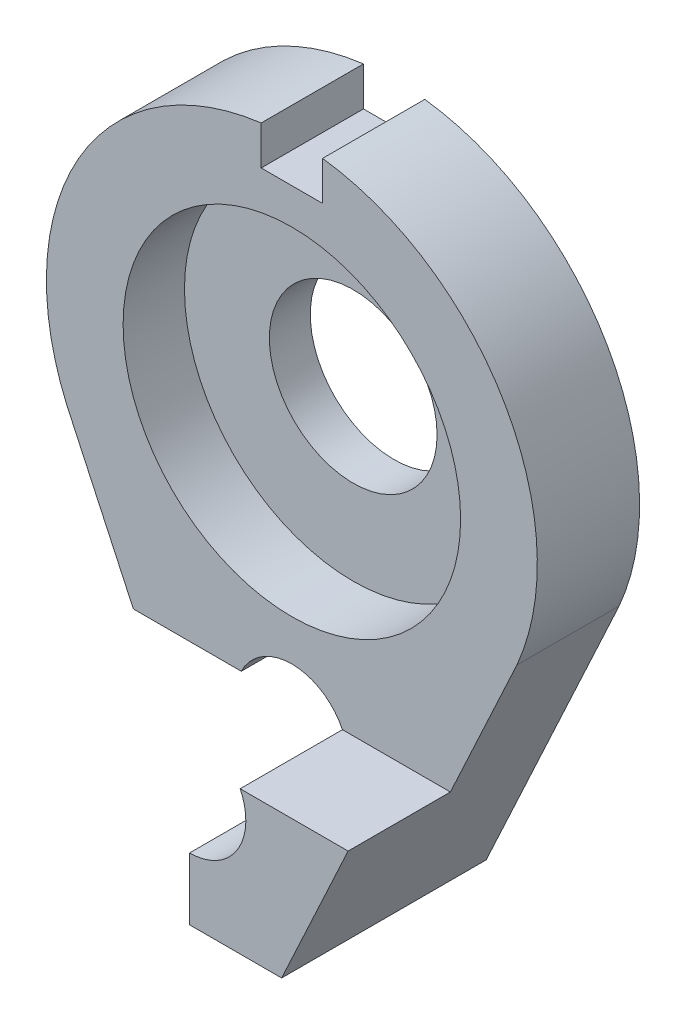
from build123d import *

# Parameters (mm, degrees)
ESQUISSE1_R                  = 4.1
BOSS_EXTRU_1_DEPTH           = 5
ESQUISSE2_R                  = 8.25
ENL_V_MAT_EXTRU_1_DEPTH      = 3
ESQUISSE4_W                  = 3
ESQUISSE4_H                  = 5
ENL_V_MAT_EXTRU_2_DEPTH      = 2
BOSS_EXTRU_2_DEPTH           = 5
ENL_V_MAT_EXTRU_4_DEPTH      = 5
ESQUISSE8_R                  = 2.75
ENL_V_MAT_EXTRU_5_DEPTH      = 6
ENL_V_MAT_EXTRU_5_DEPTH_BACK = 6


with BuildPart() as part:
    # Esquisse1 → Boss.-Extru.1 (new body)
    with BuildSketch(Plane.XY):
        with BuildLine():
            Line((-11, -4.795831523), (-4.5, -18.795831523))
            Line((-4.5, -18.795831523), (4.5, -18.795831523))
            Line((4.5, -18.795831523), (11, -4.795831523))
            ThreePointArc((11, -4.795831523), (0, 12), (-11, -4.795831523))
        make_face()
        Circle(ESQUISSE1_R, mode=Mode.SUBTRACT)
    extrude(amount=BOSS_EXTRU_1_DEPTH)

    # Esquisse2 → Enlèv. mat.-Extru.1 (cut)
    with BuildSketch(Plane.XY.offset(5)):
        Circle(ESQUISSE2_R)
    extrude(amount=-ENL_V_MAT_EXTRU_1_DEPTH, mode=Mode.SUBTRACT)

    # Esquisse4 → Enlèv. mat.-Extru.2 (cut)
    with BuildSketch(Plane(origin=(0, 12, 0), x_dir=(1, 0, 0), z_dir=(0, 1, 0))):
        with Locations((0, -2.5)):
            Rectangle(ESQUISSE4_W, ESQUISSE4_H)
    extrude(amount=-ENL_V_MAT_EXTRU_2_DEPTH, mode=Mode.SUBTRACT)

    # Esquisse6 → Boss.-Extru.2 (add)
    with BuildSketch(Plane.XY.offset(5)):
        Polygon((0, -18.795831523), (4.5, -18.795831523), (7.75, -11.795831523), (0, -11.795831523), align=None)
    extrude(amount=BOSS_EXTRU_2_DEPTH)

    # Esquisse7 → Enlèv. mat.-Extru.4 (cut)
    with BuildSketch(Plane.XY.offset(5)):
        Polygon((0, -18.795831523), (0, -11.795831523), (-7.75, -11.795831523), (-4.5, -18.795831523), align=None)
    extrude(amount=-ENL_V_MAT_EXTRU_4_DEPTH, mode=Mode.SUBTRACT)

    # Esquisse8 → Enlèv. mat.-Extru.5 (cut, two sides)
    with BuildSketch(Plane.XY.offset(5)) as enl_v_mat_extru_5_sk:
        with Locations((0, -13)):
            Circle(ESQUISSE8_R)
    extrude(amount=ENL_V_MAT_EXTRU_5_DEPTH, mode=Mode.SUBTRACT)
    extrude(enl_v_mat_extru_5_sk.sketch, amount=-ENL_V_MAT_EXTRU_5_DEPTH_BACK, mode=Mode.SUBTRACT)


solid = part.part
